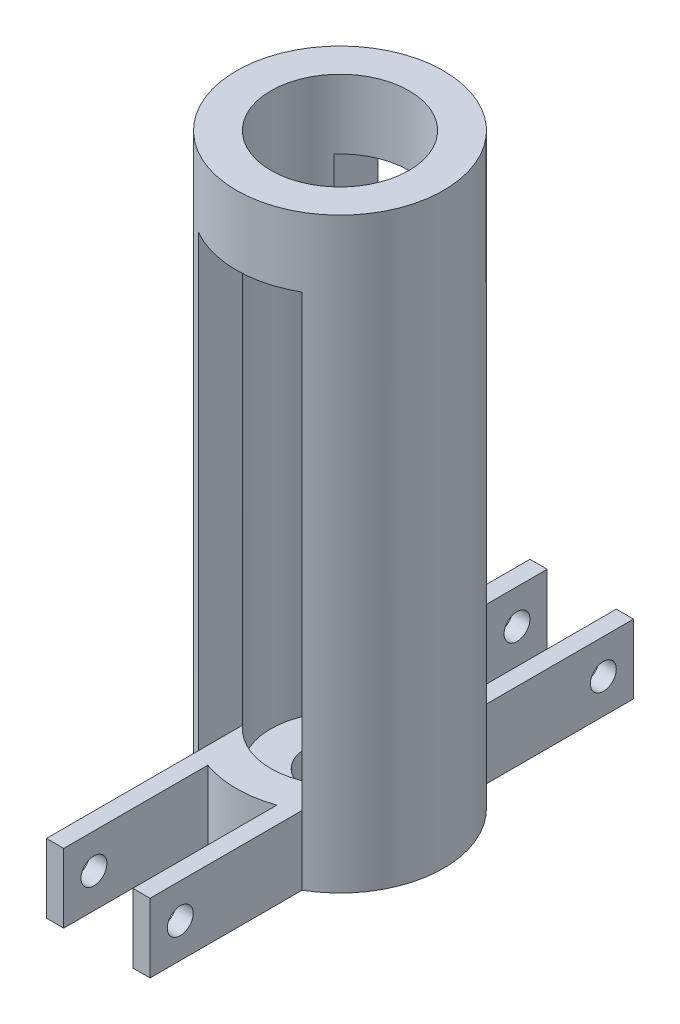
from build123d import *

# Parameters (mm, degrees)
SKETCH1_R                = 19.05
SKETCH1_R_2              = 12.7
BOSS_EXTRUDE1_DEPTH      = 107.95
SKETCH2_R                = 13.97
BOSS_EXTRUDE2_DEPTH      = 6.35
CUT_EXTRUDE6_DEPTH       = 112.260988221
CUT_EXTRUDE6_DEPTH_BACK  = 112.260988221
SKETCH8_W                = 19.05
SKETCH8_H                = 82.55
SKETCH7_R                = 6.35
CUT_EXTRUDE4_DEPTH       = 106.111203019
BOSS_EXTRUDE3_DEPTH      = 6.35
BOSS_EXTRUDE3_DEPTH_BACK = 6.35
SKETCH9_W                = 3.175
SKETCH9_H                = 27.952216058
SKETCH10_R               = 2.38125
CUT_EXTRUDE7_DEPTH       = 121.189582015


with BuildPart() as part:
    # Sketch1 → Boss-Extrude1 (new body)
    with BuildSketch(Plane(origin=(0, 0, 0), x_dir=(1, 0, 0), z_dir=(0, 1, 0))):
        Circle(SKETCH1_R)
        Circle(SKETCH1_R_2, mode=Mode.SUBTRACT)
    extrude(amount=BOSS_EXTRUDE1_DEPTH)

    # Sketch2 → Boss-Extrude2 (add)
    with BuildSketch(Plane.XZ):
        Circle(SKETCH2_R)
    extrude(amount=-BOSS_EXTRUDE2_DEPTH)

    # Sketch8 → Cut-Extrude6 (cut, two sides: drawn at the far end of the back side and taken through both)
    with BuildSketch(Plane.XY.offset(-CUT_EXTRUDE6_DEPTH_BACK)):
        with Locations((0, 53.975)):
            Rectangle(SKETCH8_W, SKETCH8_H)
    extrude(amount=CUT_EXTRUDE6_DEPTH + CUT_EXTRUDE6_DEPTH_BACK, mode=Mode.SUBTRACT)

    # Sketch7 → Cut-Extrude4 (cut, through all)
    with BuildSketch(Plane(origin=(0, 6.35, 0), x_dir=(1, 0, 0), z_dir=(0, 1, 0))):
        Circle(SKETCH7_R)
    extrude(amount=-CUT_EXTRUDE4_DEPTH, mode=Mode.SUBTRACT)

    # Sketch9 → Boss-Extrude3 (add, two sides: drawn at the far end of the back side and taken through both)
    with BuildSketch(Plane(origin=(0, 6.35, 0), x_dir=(1, 0, 0), z_dir=(0, 1, 0)).offset(-BOSS_EXTRUDE3_DEPTH_BACK)):
        with Locations((-7.9375, -30.473891971)):
            Rectangle(SKETCH9_W, SKETCH9_H)
        with Locations((7.9375, -30.473891971)):
            Rectangle(SKETCH9_W, SKETCH9_H)
        with Locations((7.9375, 30.473891971)):
            Rectangle(SKETCH9_W, SKETCH9_H)
        with Locations((-7.9375, 30.473891971)):
            Rectangle(SKETCH9_W, SKETCH9_H)
    extrude(amount=BOSS_EXTRUDE3_DEPTH + BOSS_EXTRUDE3_DEPTH_BACK)

    # Sketch10 → Cut-Extrude7 (cut, through all)
    with BuildSketch(Plane.ZY.offset(9.525)):
        with Locations((-38.89375, 6.35)):
            Circle(SKETCH10_R)
        with Locations((38.89375, 6.35)):
            Circle(SKETCH10_R)
    extrude(amount=-CUT_EXTRUDE7_DEPTH, mode=Mode.SUBTRACT)


solid = part.part
